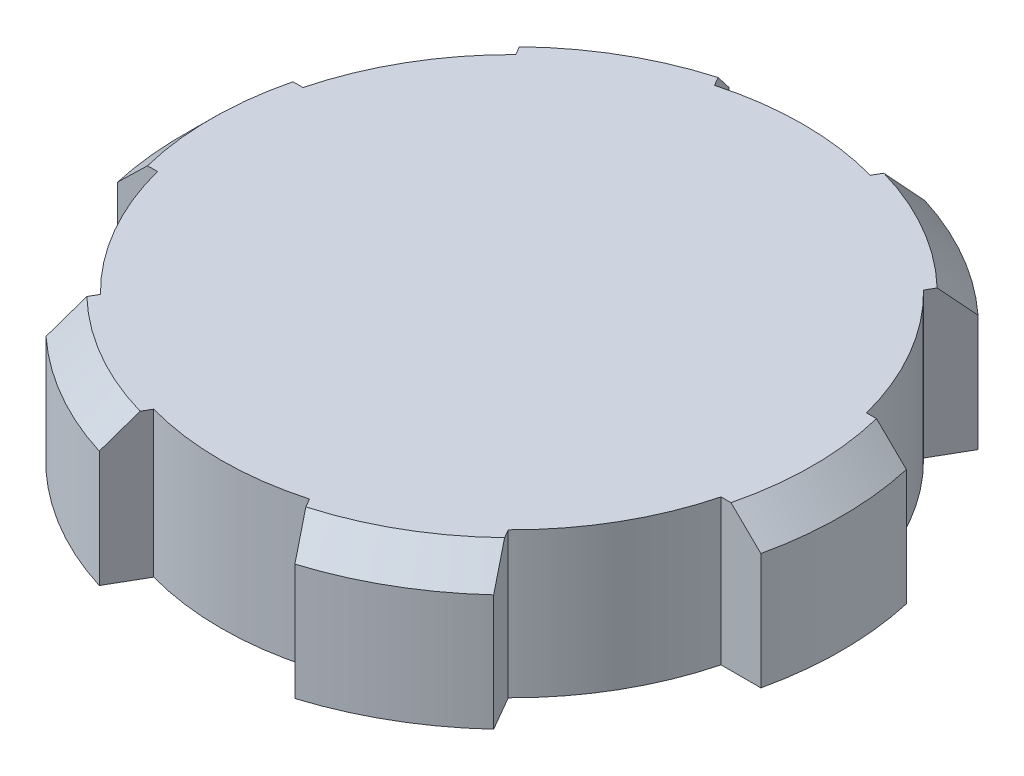
from build123d import *

# Parameters (mm, degrees)
SKETCH_1_R               = 10
EXTRUDE_1_DEPTH          = 5
EXTRUDE_2_DEPTH          = 5
PATTERN_CIRCULAR_1_COUNT = 3
PATTERN_CIRCULAR_1_ANGLE = 120
CHAMFER_1_SIZE           = 1


with BuildPart() as part:
    # 草图1 → 凸台-拉伸1 (new body)
    with BuildSketch(Plane(origin=(0, 0, 0), x_dir=(1, 0, 0), z_dir=(0, 1, 0))):
        Circle(SKETCH_1_R)
    extrude(amount=EXTRUDE_1_DEPTH)

    # 草图2 → 凸台-拉伸2 (add)
    with BuildSketch(Plane(origin=(0, 5, 0), x_dir=(1, 0, 0), z_dir=(0, 1, 0))):
        with BuildLine():
            Line((9.682458366, 2.5), (11.052828845, 2.5))
            ThreePointArc((11.052828845, 2.5), (11.332035363, 0), (11.052828845, -2.5))
            Line((11.052828845, -2.5), (9.682458366, -2.5))
            ThreePointArc((9.682458366, -2.5), (10, 0), (9.682458366, 2.5))
        make_face()
        with BuildLine():
            Line((-11.052828845, -2.5), (-9.682458366, -2.5))
            ThreePointArc((-9.682458366, -2.5), (-10, 0), (-9.682458366, 2.5))
            Line((-9.682458366, 2.5), (-11.052828845, 2.5))
            ThreePointArc((-11.052828845, 2.5), (-11.332035363, 0), (-11.052828845, -2.5))
        make_face()
    extrude_2 = extrude(amount=-EXTRUDE_2_DEPTH)

    # 阵列(圆周)1: 凸台-拉伸2 ×3 about axis
    pattern_circular_1_axis = Axis((0, 0, 0), (0, -1, 0))
    for i in range(1, PATTERN_CIRCULAR_1_COUNT):
        add(extrude_2.rotate(pattern_circular_1_axis, i * PATTERN_CIRCULAR_1_ANGLE / (PATTERN_CIRCULAR_1_COUNT - 1)))

    # 倒角1
    chamfer_1_edges = [part.edges().sort_by_distance(p)[0] for p in [
        (-11.332035363, 5, 0),
        (5.666017682, 5, 9.813830501),
        (-5.666017682, 5, -9.813830501),
        (-5.666017682, 5, 9.813830501),
        (5.666017682, 5, -9.813830501),
        (11.332035363, 5, 0),
    ]]
    chamfer(chamfer_1_edges, length=CHAMFER_1_SIZE)


solid = part.part
